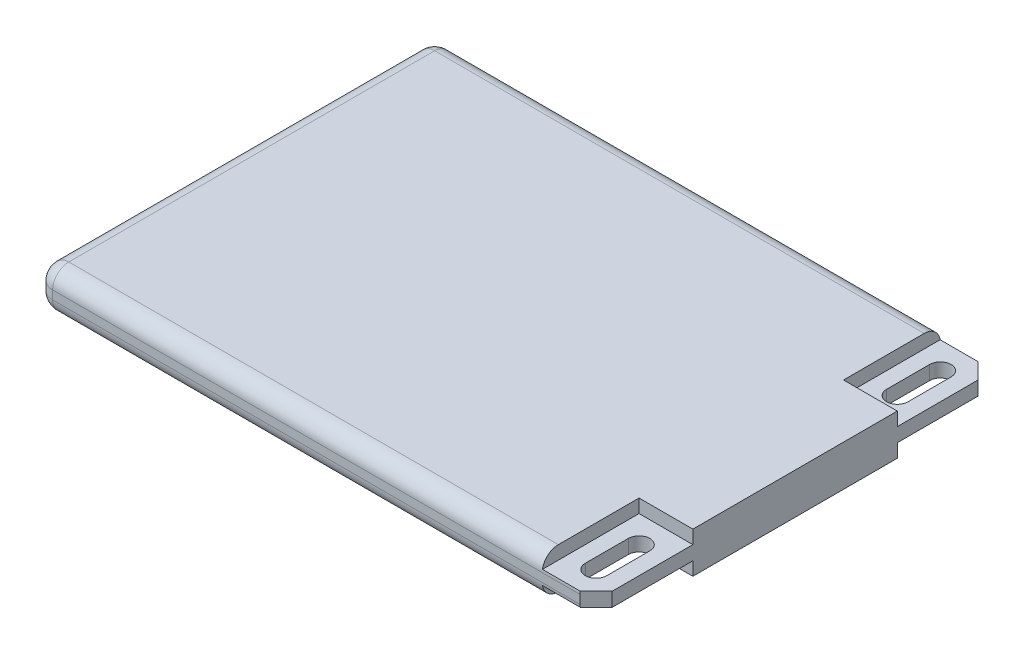
from build123d import *

# Parameters (mm, degrees)
SKETCH1_W           = 52
SKETCH1_H           = 37
BOSS_EXTRUDE1_DEPTH = 1.9
SKETCH2_W           = 5
SKETCH2_H           = 9
CUT_EXTRUDE1_DEPTH  = 1.25
CUT_EXTRUDE2_DEPTH  = 3.55
CHAMFER1_SIZE       = 1.5
FILLET2_R           = 1.5


with BuildPart() as part:
    # Sketch1 → Boss-Extrude1 (new body, symmetric)
    with BuildSketch(Plane(origin=(0, 0, 0), x_dir=(1, 0, 0), z_dir=(0, 1, 0))):
        Rectangle(SKETCH1_W, SKETCH1_H)
    extrude(amount=BOSS_EXTRUDE1_DEPTH, both=True)

    # Sketch2 → Cut-Extrude1 (cut)
    with BuildSketch(Plane(origin=(0, 1.9, 0), x_dir=(1, 0, 0), z_dir=(0, 1, 0))):
        with Locations((23.5, 14)):
            Rectangle(SKETCH2_W, SKETCH2_H)
        with Locations((23.5, -14)):
            Rectangle(SKETCH2_W, SKETCH2_H)
    cut_extrude1 = extrude(amount=-CUT_EXTRUDE1_DEPTH, mode=Mode.SUBTRACT)

    # Mirror1: Cut-Extrude1 across plane
    add(cut_extrude1.mirror(Plane.ZX), mode=Mode.SUBTRACT)

    # Sketch3 → Cut-Extrude2 (cut, through all)
    with BuildSketch(Plane(origin=(0, 0.65, 0), x_dir=(1, 0, 0), z_dir=(0, 1, 0))):
        with BuildLine():
            Line((22.5, 12), (22.5, 16))
            ThreePointArc((22.5, 16), (23.5, 17), (24.5, 16))
            Line((24.5, 16), (24.5, 12))
            ThreePointArc((24.5, 12), (23.5, 11), (22.5, 12))
        make_face()
        with BuildLine():
            Line((22.5, -12), (22.5, -16))
            ThreePointArc((22.5, -16), (23.5, -17), (24.5, -16))
            Line((24.5, -16), (24.5, -12))
            ThreePointArc((24.5, -12), (23.5, -11), (22.5, -12))
        make_face()
    extrude(amount=-CUT_EXTRUDE2_DEPTH, mode=Mode.SUBTRACT)

    # Chamfer1
    chamfer1_edges = [part.edges().sort_by_distance(p)[0] for p in [
        (26, 0, -18.5),
        (26, 0, 18.5),
    ]]
    chamfer(chamfer1_edges, length=CHAMFER1_SIZE)

    # Fillet2
    fillet2_edges = [part.edges().sort_by_distance(p)[0] for p in [
        (-2.5, -1.9, -18.5),
        (-26, 0, -18.5),
        (-26, 0, 18.5),
        (-26, -1.9, 0),
        (-2.5, -1.9, 18.5),
        (-2.5, 1.9, 18.5),
        (-26, 1.9, 0),
        (-2.5, 1.9, -18.5),
    ]]
    fillet(fillet2_edges, radius=FILLET2_R)


solid = part.part
